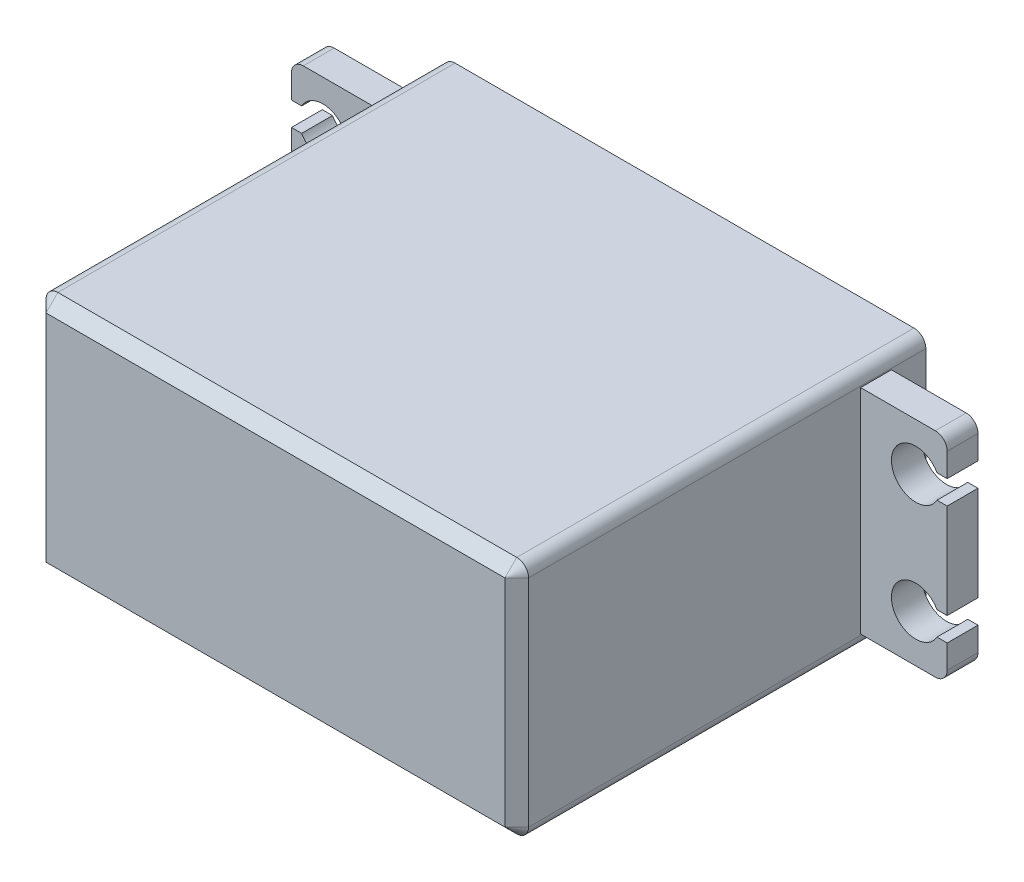
from build123d import *

# Parameters (mm, degrees)
SKETCH1_W            = 40.7
SKETCH1_H            = 20.2
BOSS_EXTRUDE1_DEPTH  = 34.5
BOSS_EXTRUDE2_DEPTH  = 2.6
FILLET2_R            = 1
FILLET2_OF_MIRROR1_R = 1
FILLET1_R            = 1
CHAMFER1_SIZE        = 1
SKETCH3_R            = 4
BOSS_EXTRUDE3_DEPTH  = 3


with BuildPart() as part:
    # Sketch1 → Boss-Extrude1 (new body)
    with BuildSketch(Plane.XY):
        Rectangle(SKETCH1_W, SKETCH1_H)
    extrude(amount=BOSS_EXTRUDE1_DEPTH)

    # Sketch2 → Boss-Extrude2 (add)
    with BuildSketch(Plane.XY.offset(5.5)):
        with BuildLine():
            Line((-20.35, 9), (-27.65, 9))
            Line((-27.65, 9), (-27.65, 6))
            Line((-27.65, 6), (-26.789553017, 6))
            ThreePointArc((-26.789553017, 6), (-22.95, 5), (-26.789553017, 4))
            Line((-26.789553017, 4), (-27.65, 4))
            Line((-27.65, 4), (-27.65, -4))
            Line((-27.65, -4), (-26.789553017, -4))
            ThreePointArc((-26.789553017, -4), (-22.95, -5), (-26.789553017, -6))
            Line((-26.789553017, -6), (-27.65, -6))
            Line((-27.65, -6), (-27.65, -9))
            Line((-27.65, -9), (-20.35, -9))
            Line((-20.35, -9), (-20.35, 9))
        make_face()
    boss_extrude2 = extrude(amount=-BOSS_EXTRUDE2_DEPTH)

    # Fillet2
    fillet2_edges = [part.edges().sort_by_distance(p)[0] for p in [
        (-27.65, -9, 4.2),
        (-27.65, 9, 4.2),
    ]]
    fillet(fillet2_edges, radius=FILLET2_R)

    # Mirror1: Boss-Extrude2 across plane
    add(boss_extrude2.mirror(Plane(origin=(0, 0, 0), x_dir=(0, 0, 1), z_dir=(1, 0, 0))))

    # Fillet2 of Mirror1
    fillet2_of_mirror1_edges = [part.edges().sort_by_distance(p)[0] for p in [
        (27.65, -9, 4.2),
        (27.65, 9, 4.2),
    ]]
    fillet(fillet2_of_mirror1_edges, radius=FILLET2_OF_MIRROR1_R)

    # Fillet1
    fillet1_edges = [part.edges().sort_by_distance(p)[0] for p in [
        (20.35, -10.1, 17.25),
        (-20.35, -10.1, 17.25),
        (-20.35, 10.1, 17.25),
        (20.35, 10.1, 17.25),
    ]]
    fillet(fillet1_edges, radius=FILLET1_R)

    # Chamfer1
    chamfer1_edges = [part.edges().sort_by_distance(p)[0] for p in [
        (-20.35, 0, 34.5),
        (20.35, 0, 34.5),
        (0, 10.1, 34.5),
        (-20.057106781, 9.807106781, 34.5),
        (20.057106781, 9.807106781, 34.5),
        (20.057106781, -9.807106781, 34.5),
        (-20.057106781, -9.807106781, 34.5),
        (0, -10.1, 34.5),
    ]]
    chamfer(chamfer1_edges, length=CHAMFER1_SIZE)

    # Sketch3 → Boss-Extrude3 (add)
    with BuildSketch(Plane(origin=(0, 0, 0), x_dir=(-1, 0, 0), z_dir=(0, 0, -1))):
        with Locations((10.35, 0)):
            Circle(SKETCH3_R)
    extrude(amount=BOSS_EXTRUDE3_DEPTH)


solid = part.part
